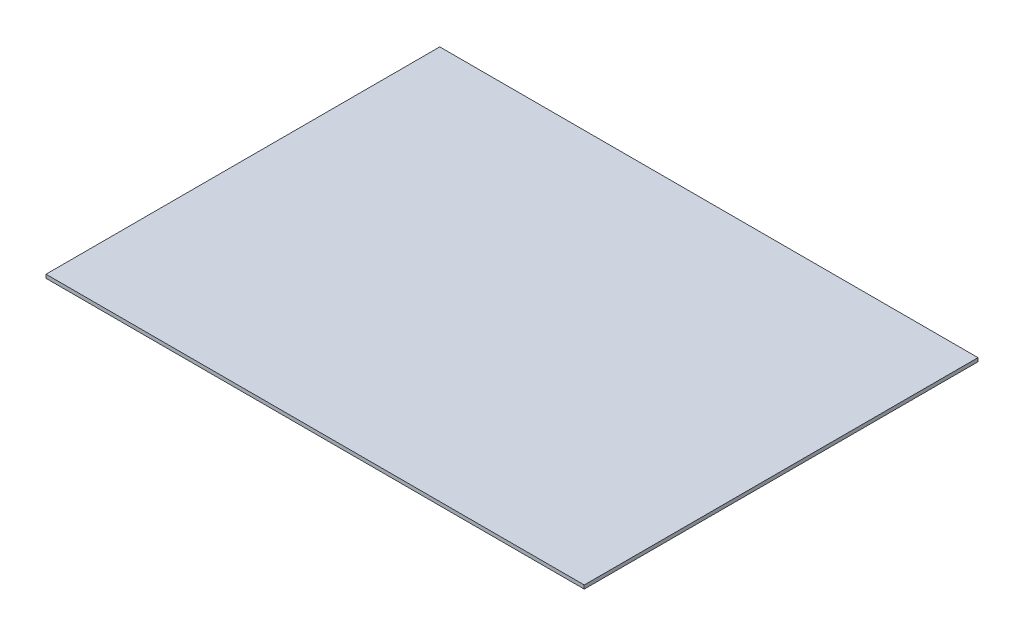
from build123d import *

# Parameters (mm, degrees)
SKETCH1_W           = 218
SKETCH1_H           = 2
BOSS_EXTRUDE1_DEPTH = 298


with BuildPart() as part:
    # Sketch1 → Boss-Extrude1 (new body)
    with BuildSketch(Plane(origin=(0, 0, 0), x_dir=(0, 0, -1), z_dir=(1, 0, 0))):
        with Locations((82.3216851, 1)):
            Rectangle(SKETCH1_W, SKETCH1_H)
    extrude(amount=BOSS_EXTRUDE1_DEPTH)


solid = part.part
